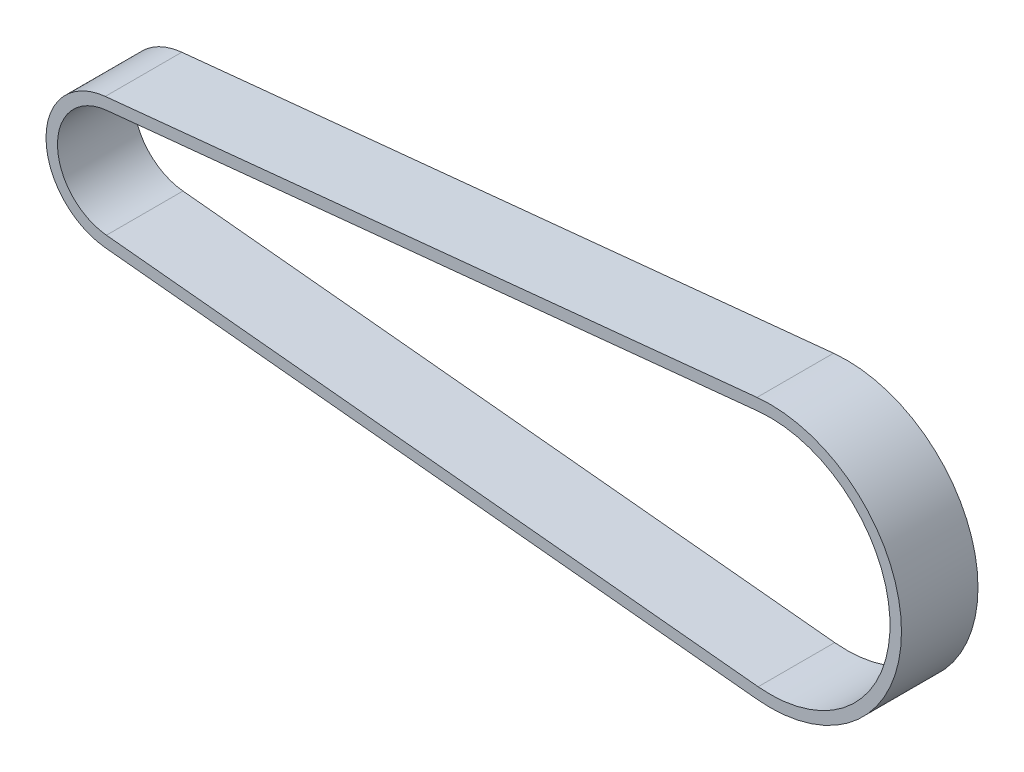
from build123d import *

# Parameters (mm, degrees)
BOSS_EXTRUDE1_DEPTH      = 9
BOSS_EXTRUDE1_DEPTH_BACK = 6


with BuildPart() as part:
    # Sketch2 → Boss-Extrude1 (new, two sides)
    with BuildSketch(Plane.XY) as boss_extrude1_sk:
        with BuildLine():
            ThreePointArc((-1.285113167, -12.8458781), (-12.91, 0), (-1.285113167, 12.8458781))
            Line((-1.285113167, 12.8458781), (126.474646488, 25.627079044))
            ThreePointArc((126.474646488, 25.627079044), (154.793402461, 0), (126.474646488, -25.627079044))
            Line((126.474646488, -25.627079044), (-1.285113167, -12.8458781))
        make_face()
        with BuildLine():
            Line((-1.061139145, 10.607053489), (126.69862051, 23.388254433))
            ThreePointArc((126.69862051, 23.388254433), (152.543402461, 0), (126.69862051, -23.388254433))
            Line((126.69862051, -23.388254433), (-1.061139145, -10.607053489))
            ThreePointArc((-1.061139145, -10.607053489), (-10.66, 0), (-1.061139145, 10.607053489))
        make_face(mode=Mode.SUBTRACT)
    extrude(amount=BOSS_EXTRUDE1_DEPTH)
    extrude(boss_extrude1_sk.sketch, amount=-BOSS_EXTRUDE1_DEPTH_BACK)


solid = part.part
